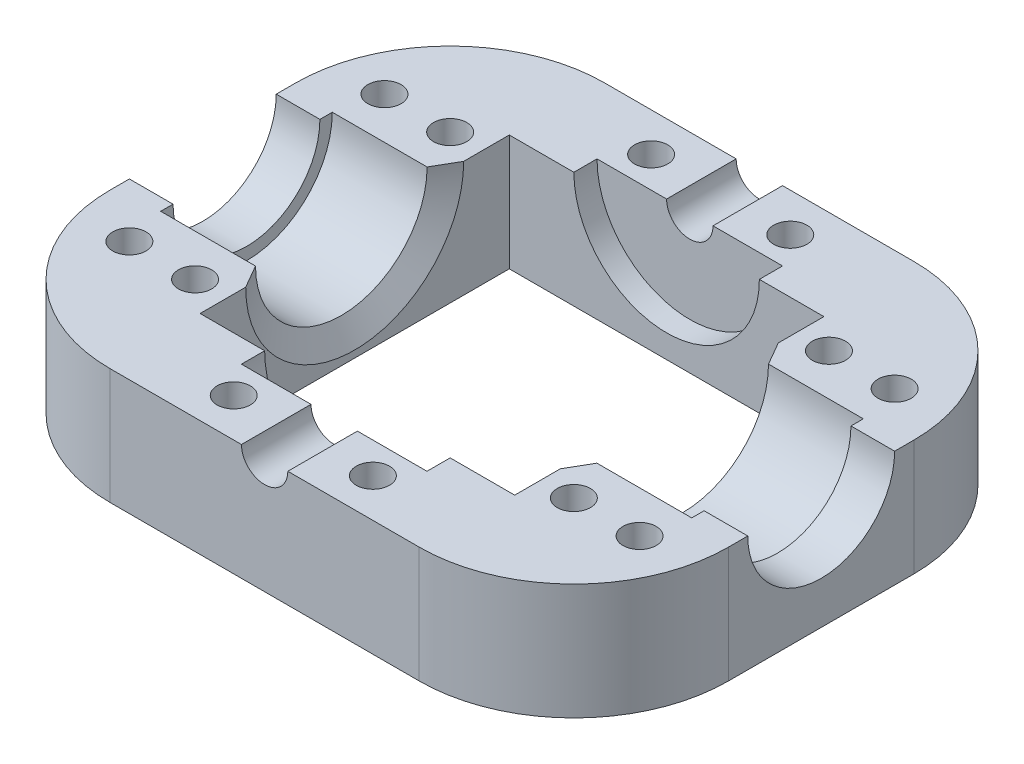
from build123d import *

# Parameters (mm, degrees)
SKETCH1_W             = 80
SKETCH1_H             = 64
SKETCH1_W_2           = 40.7
SKETCH1_H_2           = 40
BOSS_EXTRUDE1_DEPTH   = 15
SKETCH3_W             = 14
SKETCH3_H             = 11.1
SKETCH4_R             = 9.5
CUT_EXTRUDE2_DEPTH    = 81
SKETCH5_R             = 3
CUT_EXTRUDE3_DEPTH    = 65
SKETCH8_R             = 2.15
CUT_EXTRUDE6_DEPTH    = 16
FILLET1_R             = 20
CHAMFER1_SIZE         = 3
CHAMFER1_SIZE2        = 1.732050808
CHAMFER1_PART_2_SIZE  = 3
CHAMFER1_PART_2_SIZE2 = 1.732050808
SKETCH9_W             = 12
SKETCH9_H             = 3


with BuildPart() as part:
    # Sketch1 → Boss-Extrude1 (new body)
    with BuildSketch(Plane(origin=(0, 0, 0), x_dir=(1, 0, 0), z_dir=(0, 1, 0))):
        Rectangle(SKETCH1_W, SKETCH1_H)
        Rectangle(SKETCH1_W_2, SKETCH1_H_2, mode=Mode.SUBTRACT)
    extrude(amount=BOSS_EXTRUDE1_DEPTH)

    # Sketch3 → Cut-Revolve1 (revolve, cut)
    with BuildSketch(Plane(origin=(0, 15, 0), x_dir=(1, 0, 0), z_dir=(0, 1, 0))):
        with Locations((27.35, -5.55)):
            Rectangle(SKETCH3_W, SKETCH3_H)
        with Locations((-27.35, -5.55)):
            Rectangle(SKETCH3_W, SKETCH3_H)
    revolve(axis=Axis((20.35, 15, 0), (1, 0, 0)), mode=Mode.SUBTRACT)

    # Sketch4 → Cut-Extrude2 (cut, through all)
    with BuildSketch(Plane(origin=(40, 0, 0), x_dir=(0, 0, -1), z_dir=(1, 0, 0))):
        with Locations((0, 15)):
            Circle(SKETCH4_R)
    extrude(amount=-CUT_EXTRUDE2_DEPTH, mode=Mode.SUBTRACT)

    # Sketch5 → Cut-Extrude3 (cut, through all)
    with BuildSketch(Plane.XY.offset(32)):
        with Locations((0, 15)):
            Circle(SKETCH5_R)
    extrude(amount=-CUT_EXTRUDE3_DEPTH, mode=Mode.SUBTRACT)

    # Sketch8 → Cut-Extrude6 (cut, through all)
    with BuildSketch(Plane(origin=(0, 15, 0), x_dir=(1, 0, 0), z_dir=(0, 1, 0))):
        with Locations((24.5, 16.5)):
            Circle(SKETCH8_R)
        with Locations((24.5, -16.5)):
            Circle(SKETCH8_R)
        with Locations((-24.5, -16.5)):
            Circle(SKETCH8_R)
        with Locations((-24.5, 16.5)):
            Circle(SKETCH8_R)
        with Locations((9, -27)):
            Circle(SKETCH8_R)
        with Locations((-9, -27)):
            Circle(SKETCH8_R)
        with Locations((-9, 27)):
            Circle(SKETCH8_R)
        with Locations((9, 27)):
            Circle(SKETCH8_R)
        with Locations((-33, 16.5)):
            Circle(SKETCH8_R)
        with Locations((33, 16.5)):
            Circle(SKETCH8_R)
        with Locations((33, -16.5)):
            Circle(SKETCH8_R)
        with Locations((-33, -16.5)):
            Circle(SKETCH8_R)
    extrude(amount=-CUT_EXTRUDE6_DEPTH, mode=Mode.SUBTRACT)

    # Fillet1
    fillet1_edges = [part.edges().sort_by_distance(p)[0] for p in [
        (-40, 7.5, -32),
        (40, 7.5, -32),
        (40, 7.5, 32),
        (-40, 7.5, 32),
    ]]
    fillet(fillet1_edges, radius=FILLET1_R)

    # Chamfer1
    chamfer1_edges = [part.edges().sort_by_distance(p)[0] for p in [
        (20.35, 3.9, 0),
    ]]
    chamfer1_side = [part.faces().sort_by_distance(p)[0] for p in [
        (20.35, 0.427200187, 0),
    ]]
    chamfer(chamfer1_edges, length=CHAMFER1_SIZE, length2=CHAMFER1_SIZE2, reference=chamfer1_side[0])

    # Chamfer1 part 2
    chamfer1_part_2_edges = [part.edges().sort_by_distance(p)[0] for p in [
        (-20.35, 3.9, 0),
    ]]
    chamfer1_part_2_side = [part.faces().sort_by_distance(p)[0] for p in [
        (-20.35, 0.427200187, 0),
    ]]
    chamfer(chamfer1_part_2_edges, length=CHAMFER1_PART_2_SIZE, length2=CHAMFER1_PART_2_SIZE2, reference=chamfer1_part_2_side[0])

    # Sketch9 → Cut-Revolve2 (revolve, cut)
    with BuildSketch(Plane(origin=(0, 15, 0), x_dir=(1, 0, 0), z_dir=(0, 1, 0))):
        with Locations((-6, -21.5)):
            Rectangle(SKETCH9_W, SKETCH9_H)
        with Locations((-6, 21.5)):
            Rectangle(SKETCH9_W, SKETCH9_H)
    revolve(axis=Axis((0, 15, -29.871415895), (0, 0, 1)), mode=Mode.SUBTRACT)


solid = part.part
